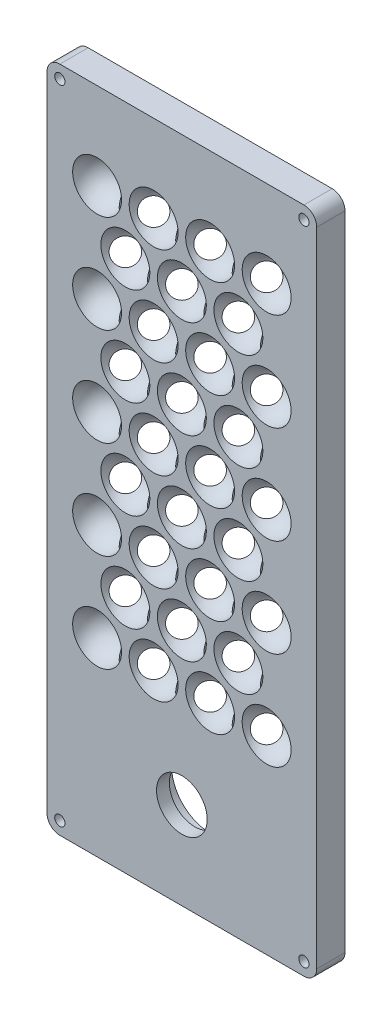
from build123d import *

# Parameters (mm, degrees)
SKETCH2_W                       = 105
SKETCH2_H                       = 260
MAIN_BODY_DEPTH                 = 10.998522628
OUTSIDE_FILLET_R                = 5
POWER_BUTTON_EXTRUDED_CUT_REACH = 12.999
SKETCH3_R                       = 9.875
F_4_0MM_DOWEL_HOLE1_D           = 4
F_4_0MM_DOWEL_HOLE1_DEPTH       = 10.998522628
SKETCH12_R                      = 15
CUT_EXTRUDE3_DEPTH              = 5.998523
LPATTERN4_COUNT                 = 4
LPATTERN4_PITCH                 = 21.997045256
LPATTERN4_COUNT_DIR2            = 5
LPATTERN4_PITCH_DIR2            = 21.997045256
LPATTERN7_COUNT                 = 7
LPATTERN7_PITCH                 = 21.997045256
LPATTERN7_COUNT_DIR2            = 9
LPATTERN7_PITCH_DIR2            = 21.997045256


with BuildPart() as part:
    # Sketch2 → main-body (new body)
    with BuildSketch(Plane.XY):
        with Locations((0, 130)):
            Rectangle(SKETCH2_W, SKETCH2_H)
    extrude(amount=MAIN_BODY_DEPTH)

    # outside-fillet
    outside_fillet_edges = [part.edges().sort_by_distance(p)[0] for p in [
        (-52.5, 260, 5.499261314),
        (52.5, 260, 5.499261314),
        (52.5, 0, 5.499261314),
        (-52.5, 0, 5.499261314),
    ]]
    fillet(outside_fillet_edges, radius=OUTSIDE_FILLET_R)

    # Sketch3 → power-button-extruded-cut (cut, up to next)
    with BuildSketch(Plane.XY.offset(10.998522628), mode=Mode.PRIVATE) as power_button_extruded_cut_sk1:
        with Locations((0, 34)):
            Circle(SKETCH3_R)
    power_button_extruded_cut_tool1 = extrude(power_button_extruded_cut_sk1.sketch, amount=-POWER_BUTTON_EXTRUDED_CUT_REACH, mode=Mode.PRIVATE) & part.part
    add(power_button_extruded_cut_tool1.solids().sort_by_distance((0, 34, 10.998523))[0], mode=Mode.SUBTRACT)

    # 4.0mm Dowel Hole1
    with Locations(Plane.XY.offset(10.998522628)):
        with Locations((-47.5, 255), (-47.5, 5), (47.5, 5), (47.5, 255)):
            Hole(F_4_0MM_DOWEL_HOLE1_D / 2, depth=F_4_0MM_DOWEL_HOLE1_DEPTH)

    # Sketch12 → Cut-Extrude3 (cut)
    with BuildSketch(Plane.XY):
        with Locations((0, 34)):
            Circle(SKETCH12_R)
    extrude(amount=CUT_EXTRUDE3_DEPTH, mode=Mode.SUBTRACT)

    # Sketch10 → Cut-Revolve1 (revolve, cut)
    with BuildSketch(Plane.XY.offset(10.998522628)):
        with BuildLine():
            Line((-20.523522628, 150), (-1.473522628, 150))
            ThreePointArc((-1.473522628, 150), (-10.998522628, 140.475), (-20.523522628, 150))
        make_face()
    cut_revolve1 = revolve(axis=Axis((-1.473522628, 150, 10.998522628), (1, 0, 0)), mode=Mode.SUBTRACT)

    # LPattern4: Cut-Revolve1 4 × 5, 10 skipped
    with Locations(*[Vector(-1, 0, 0) * (i * LPATTERN4_PITCH) + Vector(0.5, -0.866025404, 0) * (j * LPATTERN4_PITCH_DIR2) for i in range(LPATTERN4_COUNT) for j in range(LPATTERN4_COUNT_DIR2) if (i, j) not in ((0, 0), (0, 2), (0, 3), (0, 4), (1, 4), (2, 0), (2, 1), (3, 0), (3, 1), (3, 2), (3, 3))]):
        add(cut_revolve1, mode=Mode.SUBTRACT)

    # Mirror3 copy 1 sketch → Mirror3 copy 1 (revolve, cut)
    with BuildSketch(Plane(origin=(-10.998522628, -19.05, 10.998522628), x_dir=(-1, 0, 0), z_dir=(0, 0, 1))):
        with BuildLine():
            Line((-20.523522628, -150), (-1.473522628, -150))
            ThreePointArc((-1.473522628, -150), (-10.998522628, -140.475), (-20.523522628, -150))
        make_face()
    revolve(axis=Axis((-9.525, 130.95, 10.998522628), (1, 0, 0)), mode=Mode.SUBTRACT)

    # Mirror3 copy 2 sketch → Mirror3 copy 2 (revolve, cut)
    with BuildSketch(Plane(origin=(21.997045256, 0, 10.998522628), x_dir=(-1, 0, 0), z_dir=(0, 0, 1))):
        with BuildLine():
            Line((-20.523522628, -150), (-1.473522628, -150))
            ThreePointArc((-1.473522628, -150), (-10.998522628, -140.475), (-20.523522628, -150))
        make_face()
    revolve(axis=Axis((23.470567884, 150, 10.998522628), (1, 0, 0)), mode=Mode.SUBTRACT)

    # Mirror3 copy 3 sketch → Mirror3 copy 3 (revolve, cut)
    with BuildSketch(Plane(origin=(10.998522628, -19.05, 10.998522628), x_dir=(-1, 0, 0), z_dir=(0, 0, 1))):
        with BuildLine():
            Line((-20.523522628, -150), (-1.473522628, -150))
            ThreePointArc((-1.473522628, -150), (-10.998522628, -140.475), (-20.523522628, -150))
        make_face()
    revolve(axis=Axis((12.472045256, 130.95, 10.998522628), (1, 0, 0)), mode=Mode.SUBTRACT)

    # Mirror3 copy 4 sketch → Mirror3 copy 4 (revolve, cut)
    with BuildSketch(Plane(origin=(0, -38.1, 10.998522628), x_dir=(-1, 0, 0), z_dir=(0, 0, 1))):
        with BuildLine():
            Line((-20.523522628, -150), (-1.473522628, -150))
            ThreePointArc((-1.473522628, -150), (-10.998522628, -140.475), (-20.523522628, -150))
        make_face()
    revolve(axis=Axis((1.473522628, 111.9, 10.998522628), (1, 0, 0)), mode=Mode.SUBTRACT)

    # Mirror3 copy 5 sketch → Mirror3 copy 5 (revolve, cut)
    with BuildSketch(Plane(origin=(-10.998522628, -57.15, 10.998522628), x_dir=(-1, 0, 0), z_dir=(0, 0, 1))):
        with BuildLine():
            Line((-20.523522628, -150), (-1.473522628, -150))
            ThreePointArc((-1.473522628, -150), (-10.998522628, -140.475), (-20.523522628, -150))
        make_face()
    revolve(axis=Axis((-9.525, 92.85, 10.998522628), (1, 0, 0)), mode=Mode.SUBTRACT)

    # Mirror3 copy 6 sketch → Mirror3 copy 6 (revolve, cut)
    with BuildSketch(Plane(origin=(21.997045256, -38.1, 10.998522628), x_dir=(-1, 0, 0), z_dir=(0, 0, 1))):
        with BuildLine():
            Line((-20.523522628, -150), (-1.473522628, -150))
            ThreePointArc((-1.473522628, -150), (-10.998522628, -140.475), (-20.523522628, -150))
        make_face()
    revolve(axis=Axis((23.470567884, 111.9, 10.998522628), (1, 0, 0)), mode=Mode.SUBTRACT)

    # Mirror3 copy 7 sketch → Mirror3 copy 7 (revolve, cut)
    with BuildSketch(Plane(origin=(10.998522628, -57.15, 10.998522628), x_dir=(-1, 0, 0), z_dir=(0, 0, 1))):
        with BuildLine():
            Line((-20.523522628, -150), (-1.473522628, -150))
            ThreePointArc((-1.473522628, -150), (-10.998522628, -140.475), (-20.523522628, -150))
        make_face()
    revolve(axis=Axis((12.472045256, 92.85, 10.998522628), (1, 0, 0)), mode=Mode.SUBTRACT)

    # Mirror3 copy 8 sketch → Mirror3 copy 8 (revolve, cut)
    with BuildSketch(Plane(origin=(0, -76.2, 10.998522628), x_dir=(-1, 0, 0), z_dir=(0, 0, 1))):
        with BuildLine():
            Line((-20.523522628, -150), (-1.473522628, -150))
            ThreePointArc((-1.473522628, -150), (-10.998522628, -140.475), (-20.523522628, -150))
        make_face()
    revolve(axis=Axis((1.473522628, 73.8, 10.998522628), (1, 0, 0)), mode=Mode.SUBTRACT)

    # Mirror3 copy 9 sketch → Mirror3 copy 9 (revolve, cut)
    with BuildSketch(Plane(origin=(21.997045256, -76.2, 10.998522628), x_dir=(-1, 0, 0), z_dir=(0, 0, 1))):
        with BuildLine():
            Line((-20.523522628, -150), (-1.473522628, -150))
            ThreePointArc((-1.473522628, -150), (-10.998522628, -140.475), (-20.523522628, -150))
        make_face()
    revolve(axis=Axis((23.470567884, 73.8, 10.998522628), (1, 0, 0)), mode=Mode.SUBTRACT)

    # Mirror3 copy 10 sketch → Mirror3 copy 10 (revolve, cut)
    with BuildSketch(Plane(origin=(0, 0, 10.998522628), x_dir=(-1, 0, 0), z_dir=(0, 0, 1))):
        with BuildLine():
            Line((-20.523522628, -150), (-1.473522628, -150))
            ThreePointArc((-1.473522628, -150), (-10.998522628, -140.475), (-20.523522628, -150))
        make_face()
    revolve(axis=Axis((1.473522628, 150, 10.998522628), (1, 0, 0)), mode=Mode.SUBTRACT)

    # Mirror3 at the second plane copy 1 sketc → Mirror3 at the second plane copy 1 (revolve, cut)
    with BuildSketch(Plane(origin=(10.998522628, 319.05, 10.998522628), x_dir=(1, 0, 0), z_dir=(0, 0, 1))):
        with BuildLine():
            Line((-20.523522628, -150), (-1.473522628, -150))
            ThreePointArc((-1.473522628, -150), (-10.998522628, -140.475), (-20.523522628, -150))
        make_face()
    revolve(axis=Axis((9.525, 169.05, 10.998522628), (-1, 0, 0)), mode=Mode.SUBTRACT)

    # Mirror3 at the second plane copy 2 sketc → Mirror3 at the second plane copy 2 (revolve, cut)
    with BuildSketch(Plane(origin=(-21.997045256, 300, 10.998522628), x_dir=(1, 0, 0), z_dir=(0, 0, 1))):
        with BuildLine():
            Line((-20.523522628, -150), (-1.473522628, -150))
            ThreePointArc((-1.473522628, -150), (-10.998522628, -140.475), (-20.523522628, -150))
        make_face()
    revolve(axis=Axis((-23.470567884, 150, 10.998522628), (-1, 0, 0)), mode=Mode.SUBTRACT)

    # Mirror3 at the second plane copy 3 sketc → Mirror3 at the second plane copy 3 (revolve, cut)
    with BuildSketch(Plane(origin=(-10.998522628, 319.05, 10.998522628), x_dir=(1, 0, 0), z_dir=(0, 0, 1))):
        with BuildLine():
            Line((-20.523522628, -150), (-1.473522628, -150))
            ThreePointArc((-1.473522628, -150), (-10.998522628, -140.475), (-20.523522628, -150))
        make_face()
    revolve(axis=Axis((-12.472045256, 169.05, 10.998522628), (-1, 0, 0)), mode=Mode.SUBTRACT)

    # Mirror3 at the second plane copy 4 sketc → Mirror3 at the second plane copy 4 (revolve, cut)
    with BuildSketch(Plane(origin=(0, 338.1, 10.998522628), x_dir=(1, 0, 0), z_dir=(0, 0, 1))):
        with BuildLine():
            Line((-20.523522628, -150), (-1.473522628, -150))
            ThreePointArc((-1.473522628, -150), (-10.998522628, -140.475), (-20.523522628, -150))
        make_face()
    revolve(axis=Axis((-1.473522628, 188.1, 10.998522628), (-1, 0, 0)), mode=Mode.SUBTRACT)

    # Mirror3 at the second plane copy 5 sketc → Mirror3 at the second plane copy 5 (revolve, cut)
    with BuildSketch(Plane(origin=(10.998522628, 357.15, 10.998522628), x_dir=(1, 0, 0), z_dir=(0, 0, 1))):
        with BuildLine():
            Line((-20.523522628, -150), (-1.473522628, -150))
            ThreePointArc((-1.473522628, -150), (-10.998522628, -140.475), (-20.523522628, -150))
        make_face()
    revolve(axis=Axis((9.525, 207.15, 10.998522628), (-1, 0, 0)), mode=Mode.SUBTRACT)

    # Mirror3 at the second plane copy 6 sketc → Mirror3 at the second plane copy 6 (revolve, cut)
    with BuildSketch(Plane(origin=(-21.997045256, 338.1, 10.998522628), x_dir=(1, 0, 0), z_dir=(0, 0, 1))):
        with BuildLine():
            Line((-20.523522628, -150), (-1.473522628, -150))
            ThreePointArc((-1.473522628, -150), (-10.998522628, -140.475), (-20.523522628, -150))
        make_face()
    revolve(axis=Axis((-23.470567884, 188.1, 10.998522628), (-1, 0, 0)), mode=Mode.SUBTRACT)

    # Mirror3 at the second plane copy 7 sketc → Mirror3 at the second plane copy 7 (revolve, cut)
    with BuildSketch(Plane(origin=(-10.998522628, 357.15, 10.998522628), x_dir=(1, 0, 0), z_dir=(0, 0, 1))):
        with BuildLine():
            Line((-20.523522628, -150), (-1.473522628, -150))
            ThreePointArc((-1.473522628, -150), (-10.998522628, -140.475), (-20.523522628, -150))
        make_face()
    revolve(axis=Axis((-12.472045256, 207.15, 10.998522628), (-1, 0, 0)), mode=Mode.SUBTRACT)

    # Mirror3 at the second plane copy 8 sketc → Mirror3 at the second plane copy 8 (revolve, cut)
    with BuildSketch(Plane(origin=(0, 376.2, 10.998522628), x_dir=(1, 0, 0), z_dir=(0, 0, 1))):
        with BuildLine():
            Line((-20.523522628, -150), (-1.473522628, -150))
            ThreePointArc((-1.473522628, -150), (-10.998522628, -140.475), (-20.523522628, -150))
        make_face()
    revolve(axis=Axis((-1.473522628, 226.2, 10.998522628), (-1, 0, 0)), mode=Mode.SUBTRACT)

    # Mirror3 at the second plane copy 9 sketc → Mirror3 at the second plane copy 9 (revolve, cut)
    with BuildSketch(Plane(origin=(-21.997045256, 376.2, 10.998522628), x_dir=(1, 0, 0), z_dir=(0, 0, 1))):
        with BuildLine():
            Line((-20.523522628, -150), (-1.473522628, -150))
            ThreePointArc((-1.473522628, -150), (-10.998522628, -140.475), (-20.523522628, -150))
        make_face()
    revolve(axis=Axis((-23.470567884, 226.2, 10.998522628), (-1, 0, 0)), mode=Mode.SUBTRACT)

    # Mirror3 at the second plane copy 10 sket → Mirror3 at the second plane copy 10 (revolve, cut)
    with BuildSketch(Plane(origin=(0, 300, 10.998522628), x_dir=(1, 0, 0), z_dir=(0, 0, 1))):
        with BuildLine():
            Line((-20.523522628, -150), (-1.473522628, -150))
            ThreePointArc((-1.473522628, -150), (-10.998522628, -140.475), (-20.523522628, -150))
        make_face()
    revolve(axis=Axis((-1.473522628, 150, 10.998522628), (-1, 0, 0)), mode=Mode.SUBTRACT)

    # Mirror3 at the second plane copy 11 sket → Mirror3 at the second plane copy 11 (revolve, cut)
    with BuildSketch(Plane(origin=(-10.998522628, 319.05, 10.998522628), x_dir=(-1, 0, 0), z_dir=(0, 0, 1))):
        with BuildLine():
            Line((-20.523522628, 150), (-1.473522628, 150))
            ThreePointArc((-1.473522628, 150), (-10.998522628, 140.475), (-20.523522628, 150))
        make_face()
    revolve(axis=Axis((-9.525, 169.05, 10.998522628), (-1, 0, 0)), mode=Mode.SUBTRACT)

    # Mirror3 at the second plane copy 12 sket → Mirror3 at the second plane copy 12 (revolve, cut)
    with BuildSketch(Plane(origin=(21.997045256, 300, 10.998522628), x_dir=(-1, 0, 0), z_dir=(0, 0, 1))):
        with BuildLine():
            Line((-20.523522628, 150), (-1.473522628, 150))
            ThreePointArc((-1.473522628, 150), (-10.998522628, 140.475), (-20.523522628, 150))
        make_face()
    revolve(axis=Axis((23.470567884, 150, 10.998522628), (-1, 0, 0)), mode=Mode.SUBTRACT)

    # Mirror3 at the second plane copy 13 sket → Mirror3 at the second plane copy 13 (revolve, cut)
    with BuildSketch(Plane(origin=(10.998522628, 319.05, 10.998522628), x_dir=(-1, 0, 0), z_dir=(0, 0, 1))):
        with BuildLine():
            Line((-20.523522628, 150), (-1.473522628, 150))
            ThreePointArc((-1.473522628, 150), (-10.998522628, 140.475), (-20.523522628, 150))
        make_face()
    revolve(axis=Axis((12.472045256, 169.05, 10.998522628), (-1, 0, 0)), mode=Mode.SUBTRACT)

    # Mirror3 at the second plane copy 14 sket → Mirror3 at the second plane copy 14 (revolve, cut)
    with BuildSketch(Plane(origin=(0, 338.1, 10.998522628), x_dir=(-1, 0, 0), z_dir=(0, 0, 1))):
        with BuildLine():
            Line((-20.523522628, 150), (-1.473522628, 150))
            ThreePointArc((-1.473522628, 150), (-10.998522628, 140.475), (-20.523522628, 150))
        make_face()
    revolve(axis=Axis((1.473522628, 188.1, 10.998522628), (-1, 0, 0)), mode=Mode.SUBTRACT)

    # Mirror3 at the second plane copy 15 sket → Mirror3 at the second plane copy 15 (revolve, cut)
    with BuildSketch(Plane(origin=(-10.998522628, 357.15, 10.998522628), x_dir=(-1, 0, 0), z_dir=(0, 0, 1))):
        with BuildLine():
            Line((-20.523522628, 150), (-1.473522628, 150))
            ThreePointArc((-1.473522628, 150), (-10.998522628, 140.475), (-20.523522628, 150))
        make_face()
    revolve(axis=Axis((-9.525, 207.15, 10.998522628), (-1, 0, 0)), mode=Mode.SUBTRACT)

    # Mirror3 at the second plane copy 16 sket → Mirror3 at the second plane copy 16 (revolve, cut)
    with BuildSketch(Plane(origin=(21.997045256, 338.1, 10.998522628), x_dir=(-1, 0, 0), z_dir=(0, 0, 1))):
        with BuildLine():
            Line((-20.523522628, 150), (-1.473522628, 150))
            ThreePointArc((-1.473522628, 150), (-10.998522628, 140.475), (-20.523522628, 150))
        make_face()
    revolve(axis=Axis((23.470567884, 188.1, 10.998522628), (-1, 0, 0)), mode=Mode.SUBTRACT)

    # Mirror3 at the second plane copy 17 sket → Mirror3 at the second plane copy 17 (revolve, cut)
    with BuildSketch(Plane(origin=(10.998522628, 357.15, 10.998522628), x_dir=(-1, 0, 0), z_dir=(0, 0, 1))):
        with BuildLine():
            Line((-20.523522628, 150), (-1.473522628, 150))
            ThreePointArc((-1.473522628, 150), (-10.998522628, 140.475), (-20.523522628, 150))
        make_face()
    revolve(axis=Axis((12.472045256, 207.15, 10.998522628), (-1, 0, 0)), mode=Mode.SUBTRACT)

    # Mirror3 at the second plane copy 18 sket → Mirror3 at the second plane copy 18 (revolve, cut)
    with BuildSketch(Plane(origin=(0, 376.2, 10.998522628), x_dir=(-1, 0, 0), z_dir=(0, 0, 1))):
        with BuildLine():
            Line((-20.523522628, 150), (-1.473522628, 150))
            ThreePointArc((-1.473522628, 150), (-10.998522628, 140.475), (-20.523522628, 150))
        make_face()
    revolve(axis=Axis((1.473522628, 226.2, 10.998522628), (-1, 0, 0)), mode=Mode.SUBTRACT)

    # Mirror3 at the second plane copy 19 sket → Mirror3 at the second plane copy 19 (revolve, cut)
    with BuildSketch(Plane(origin=(21.997045256, 376.2, 10.998522628), x_dir=(-1, 0, 0), z_dir=(0, 0, 1))):
        with BuildLine():
            Line((-20.523522628, 150), (-1.473522628, 150))
            ThreePointArc((-1.473522628, 150), (-10.998522628, 140.475), (-20.523522628, 150))
        make_face()
    revolve(axis=Axis((23.470567884, 226.2, 10.998522628), (-1, 0, 0)), mode=Mode.SUBTRACT)

    # Mirror3 at the second plane copy 20 sket → Mirror3 at the second plane copy 20 (revolve, cut)
    with BuildSketch(Plane(origin=(0, 300, 10.998522628), x_dir=(-1, 0, 0), z_dir=(0, 0, 1))):
        with BuildLine():
            Line((-20.523522628, 150), (-1.473522628, 150))
            ThreePointArc((-1.473522628, 150), (-10.998522628, 140.475), (-20.523522628, 150))
        make_face()
    revolve(axis=Axis((1.473522628, 150, 10.998522628), (-1, 0, 0)), mode=Mode.SUBTRACT)

    # Mirror3 at the second plane copy 21 sket → Mirror3 at the second plane copy 21 (revolve, cut)
    with BuildSketch(Plane(origin=(0, 300, 10.998522628), x_dir=(1, 0, 0), z_dir=(0, 0, 1))):
        with BuildLine():
            Line((-20.523522628, -150), (-1.473522628, -150))
            ThreePointArc((-1.473522628, -150), (-10.998522628, -140.475), (-20.523522628, -150))
        make_face()
    revolve(axis=Axis((-1.473522628, 150, 10.998522628), (-1, 0, 0)), mode=Mode.SUBTRACT)

    # Sketch11 → Cut-Revolve2 (revolve, cut)
    with BuildSketch(Plane(origin=(0, 0, 0), x_dir=(-1, 0, 0), z_dir=(0, 0, -1))):
        with BuildLine():
            Line((-31.522045256, 219.85), (-12.472045256, 219.85))
            ThreePointArc((-12.472045256, 219.85), (-21.997045256, 210.325), (-31.522045256, 219.85))
        make_face()
    cut_revolve2 = revolve(axis=Axis((12.472045256, 219.85, 0), (-1, 0, 0)), mode=Mode.SUBTRACT)

    # LPattern7: Cut-Revolve2 7 × 9, 32 skipped
    with Locations(*[Vector(-1, 0, 0) * (i * LPATTERN7_PITCH) + Vector(0.5, -0.866025404, 0) * (j * LPATTERN7_PITCH_DIR2) for i in range(LPATTERN7_COUNT) for j in range(LPATTERN7_COUNT_DIR2) if (i, j) not in ((0, 0), (0, 2), (0, 3), (0, 4), (0, 5), (0, 6), (0, 7), (0, 8), (1, 4), (1, 5), (1, 6), (1, 7), (1, 8), (2, 6), (2, 7), (2, 8), (3, 0), (3, 8), (4, 0), (4, 1), (4, 2), (5, 0), (5, 1), (5, 2), (5, 3), (5, 4), (6, 0), (6, 1), (6, 2), (6, 3), (6, 4), (6, 5), (6, 6))]):
        add(cut_revolve2, mode=Mode.SUBTRACT)


solid = part.part
